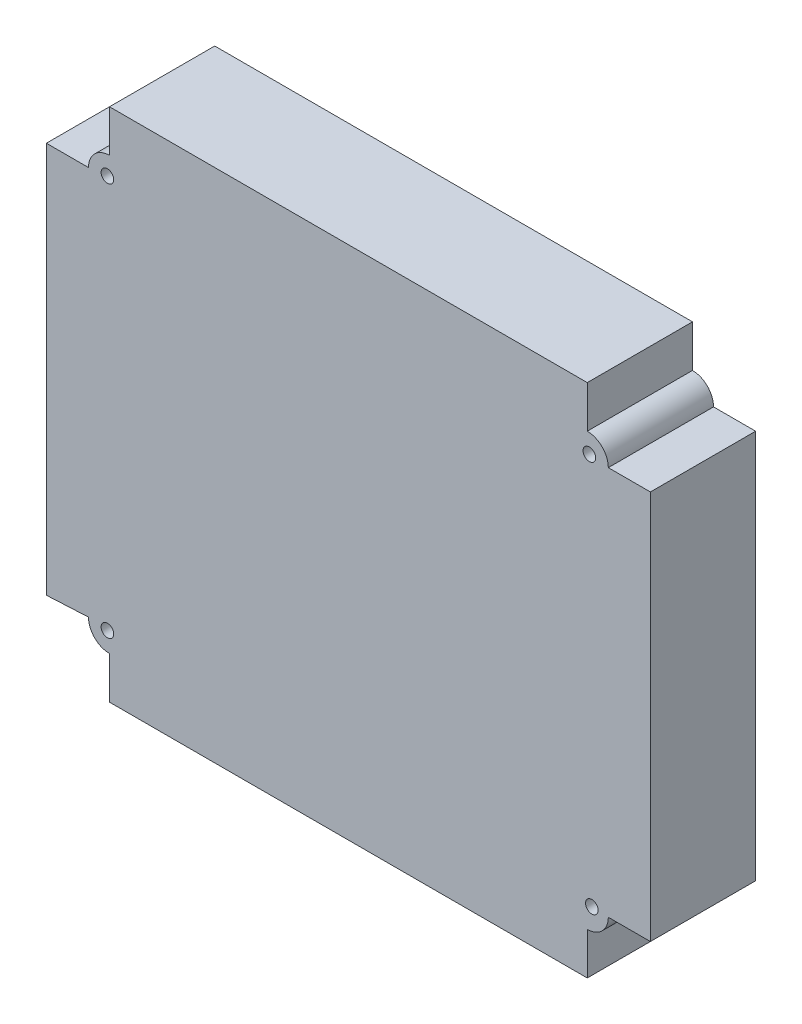
from build123d import *

# Parameters (mm, degrees)
SKETCH_1_R      = 1.5
EXTRUDE_1_DEPTH = 25


with BuildPart() as part:
    # 草图1 → 凸台-拉伸1 (new body)
    with BuildSketch(Plane.XY):
        with BuildLine():
            Line((-119.48625, 97.5), (-129.48625, 97.5))
            Line((-129.48625, 97.5), (-129.48625, 4.5))
            Line((-129.48625, 4.5), (-119.48625, 5))
            ThreePointArc((-119.48625, 5), (-118.021783906, 1.464466094), (-114.48625, 0))
            Line((-114.48625, 0), (-114.48625, -10))
            Line((-114.48625, -10), (-0.98625, -10))
            Line((-0.98625, -10), (-0.98625, 0))
            ThreePointArc((-0.98625, 0), (2.549283906, 1.464466094), (4.01375, 5))
            Line((4.01375, 5), (14.01375, 5))
            Line((14.01375, 5), (14.01375, 97.5))
            Line((14.01375, 97.5), (4.01375, 97.5))
            ThreePointArc((4.01375, 97.5), (2.549283906, 101.035533906), (-0.98625, 102.5))
            Line((-0.98625, 102.5), (-0.98625, 112.5))
            Line((-0.98625, 112.5), (-114.48625, 112.5))
            Line((-114.48625, 112.5), (-114.48625, 102.5))
            ThreePointArc((-114.48625, 102.5), (-118.021783906, 101.035533906), (-119.48625, 97.5))
        make_face()
        with Locations((-114.98625, 98)):
            Circle(SKETCH_1_R, mode=Mode.SUBTRACT)
        with Locations((-114.98625, 4.5)):
            Circle(SKETCH_1_R, mode=Mode.SUBTRACT)
        with Locations((0.095685547, 5.201161366)):
            Circle(SKETCH_1_R, mode=Mode.SUBTRACT)
        with Locations((-0.48625, 98)):
            Circle(SKETCH_1_R, mode=Mode.SUBTRACT)
    extrude(amount=EXTRUDE_1_DEPTH)


solid = part.part
